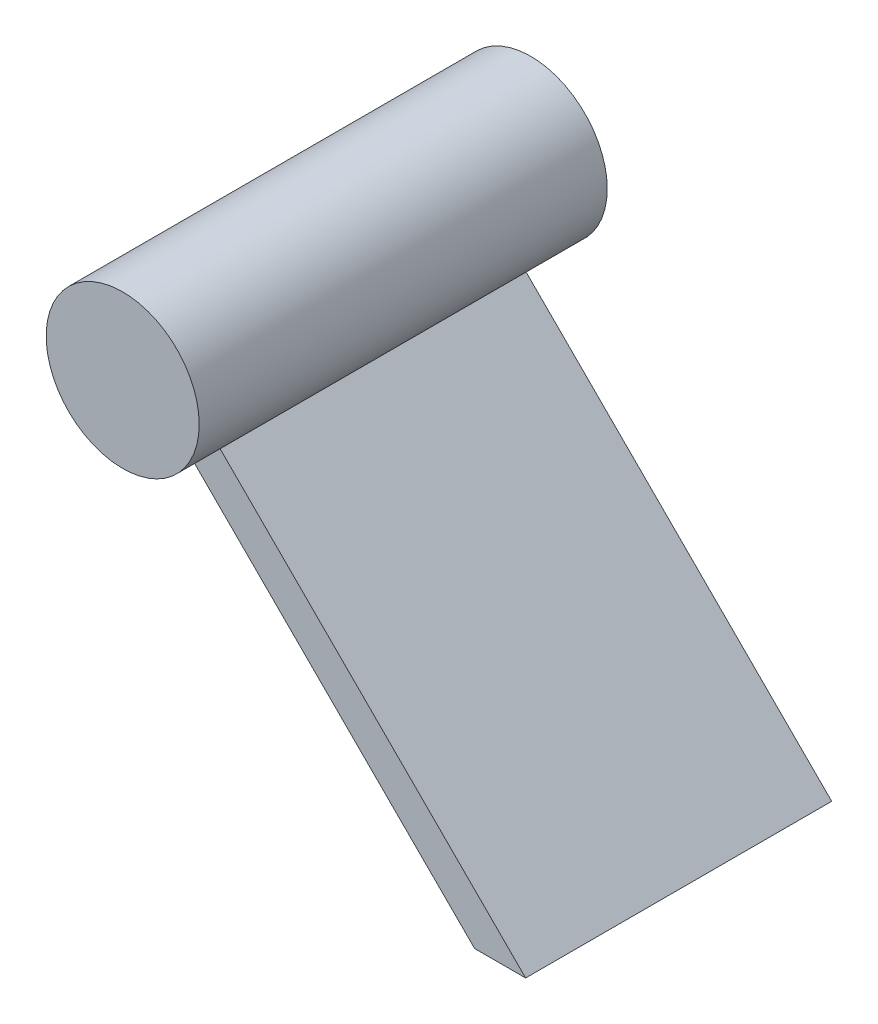
from build123d import *

# Parameters (mm, degrees)
BOSS_EXTRUDE2_DEPTH = 15
SKETCH3_3_R         = 7.5
BOSS_EXTRUDE3_DEPTH = 20


with BuildPart() as part:
    # Sketch3 → Boss-Extrude2 (new body, symmetric)
    with BuildSketch(Plane.XY):
        Polygon((0, 0), (30, -30), (35, -30), (5, 0), align=None)
    extrude(amount=BOSS_EXTRUDE2_DEPTH, both=True)

    # Sketch3_3 → Boss-Extrude3 (add, symmetric)
    with BuildSketch(Plane.XY):
        with Locations((0.5, 6)):
            Circle(SKETCH3_3_R)
    extrude(amount=BOSS_EXTRUDE3_DEPTH, both=True)


solid = part.part
